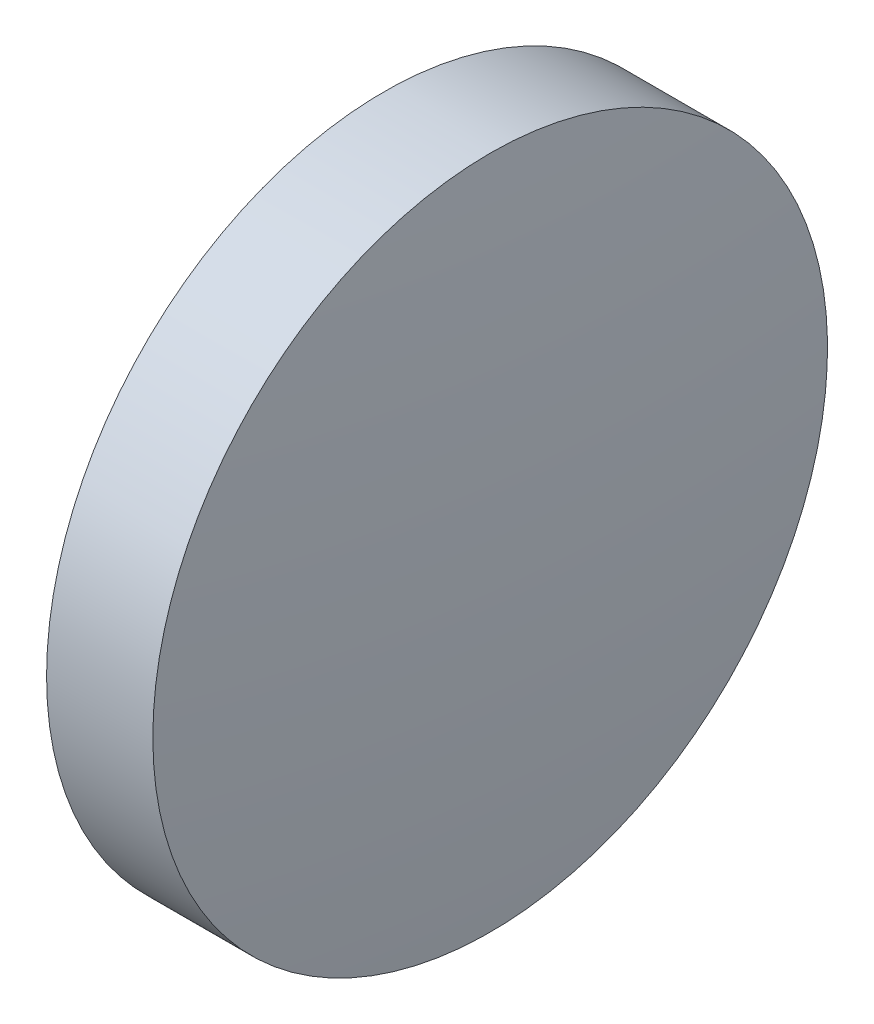
from build123d import *


with BuildPart() as part:
    # 草图1 → 旋转1 (revolve)
    with BuildSketch(Plane.XY):
        with BuildLine():
            Line((46.302567292, 26.093421971), (46.302567292, 32.443421971))
            Line((46.302567292, 32.443421971), (48.302567292, 32.443421971))
            ThreePointArc((48.302567292, 32.443421971), (48.527525488, 29.271963303), (48.602567292, 26.093421971))
            Line((48.602567292, 26.093421971), (46.302567292, 26.093421971))
        make_face()
    revolve(axis=Axis((44.066149291, 26.093421971, 0), (1, 0, 0)))


solid = part.part
